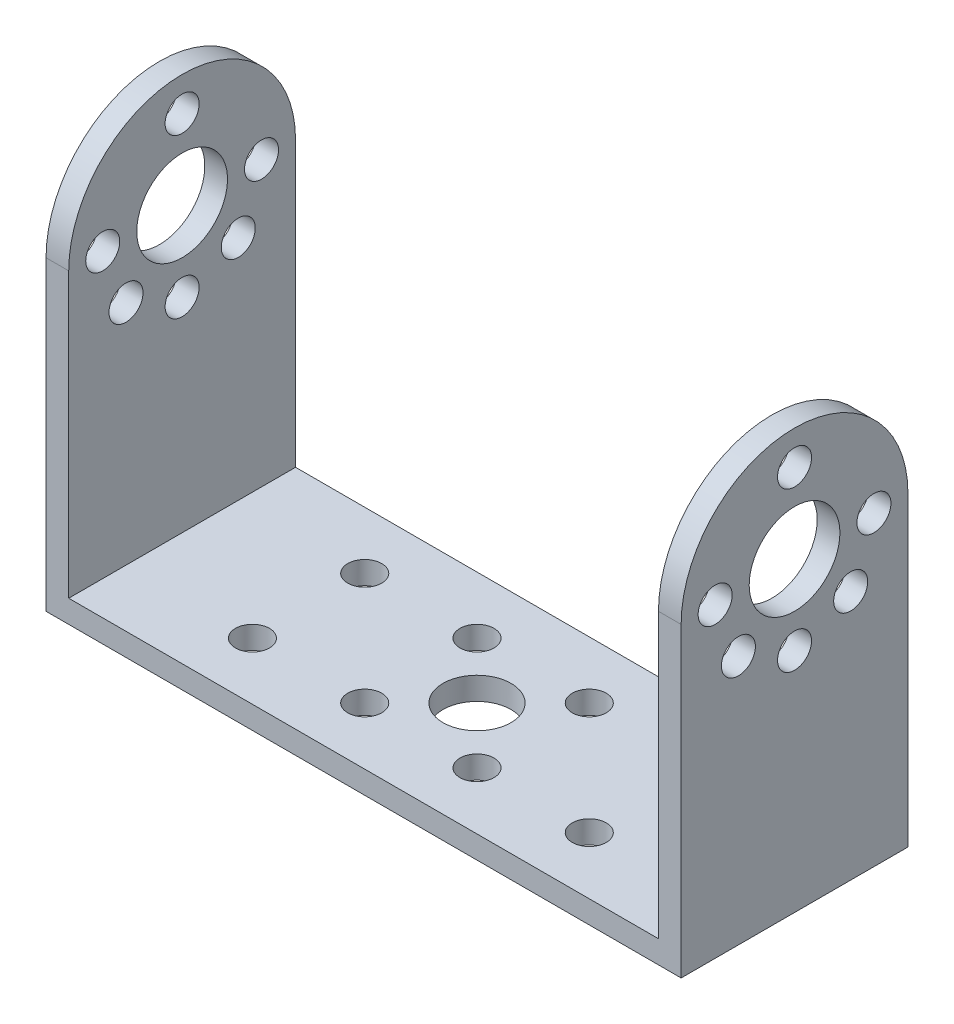
from build123d import *

# Parameters (mm, degrees)
SKETCH_1_W          = 56
SKETCH_1_H          = 20
EXTRUDE_1_DEPTH     = 2
CUT_EXTRUDE_1_REACH = 4
SKETCH_2_R          = 3
SKETCH_2_R_2        = 1.5
EXTRUDE_2_DEPTH     = 2
SKETCH_4_R          = 4
SKETCH_4_R_2        = 1.5
CUT_EXTRUDE_2_DEPTH = 2


with BuildPart() as part:
    # 草图1 → 凸台-拉伸1 (new body)
    with BuildSketch(Plane(origin=(0, 0, 0), x_dir=(1, 0, 0), z_dir=(0, 1, 0))):
        with Locations((28, 10)):
            Rectangle(SKETCH_1_W, SKETCH_1_H)
    extrude(amount=EXTRUDE_1_DEPTH)

    # 草图2 → 切除-拉伸1 (cut, up to next)
    with BuildSketch(Plane(origin=(0, 2, 0), x_dir=(1, 0, 0), z_dir=(0, 1, 0)), mode=Mode.PRIVATE) as cut_extrude_1_sk1:
        with Locations((28, 10)):
            Circle(SKETCH_2_R)
    cut_extrude_1_tool1 = extrude(cut_extrude_1_sk1.sketch, amount=-CUT_EXTRUDE_1_REACH, mode=Mode.PRIVATE) & part.part
    add(cut_extrude_1_tool1.solids().sort_by_distance((28, 2, -10))[0], mode=Mode.SUBTRACT)
    # 草图2 → 切除-拉伸1 (cut, up to next)
    with BuildSketch(Plane(origin=(0, 2, 0), x_dir=(1, 0, 0), z_dir=(0, 1, 0)), mode=Mode.PRIVATE) as cut_extrude_1_sk2:
        with Locations((32.949747468, 5.050252532)):
            Circle(SKETCH_2_R_2)
    cut_extrude_1_tool2 = extrude(cut_extrude_1_sk2.sketch, amount=-CUT_EXTRUDE_1_REACH, mode=Mode.PRIVATE) & part.part
    add(cut_extrude_1_tool2.solids().sort_by_distance((32.949747, 2, -5.050253))[0], mode=Mode.SUBTRACT)
    # 草图2 → 切除-拉伸1 (cut, up to next)
    with BuildSketch(Plane(origin=(0, 2, 0), x_dir=(1, 0, 0), z_dir=(0, 1, 0)), mode=Mode.PRIVATE) as cut_extrude_1_sk3:
        with Locations((23.050252532, 5.050252532)):
            Circle(SKETCH_2_R_2)
    cut_extrude_1_tool3 = extrude(cut_extrude_1_sk3.sketch, amount=-CUT_EXTRUDE_1_REACH, mode=Mode.PRIVATE) & part.part
    add(cut_extrude_1_tool3.solids().sort_by_distance((23.050253, 2, -5.050253))[0], mode=Mode.SUBTRACT)
    # 草图2 → 切除-拉伸1 (cut, up to next)
    with BuildSketch(Plane(origin=(0, 2, 0), x_dir=(1, 0, 0), z_dir=(0, 1, 0)), mode=Mode.PRIVATE) as cut_extrude_1_sk4:
        with Locations((23.050252532, 14.949747468)):
            Circle(SKETCH_2_R_2)
    cut_extrude_1_tool4 = extrude(cut_extrude_1_sk4.sketch, amount=-CUT_EXTRUDE_1_REACH, mode=Mode.PRIVATE) & part.part
    add(cut_extrude_1_tool4.solids().sort_by_distance((23.050253, 2, -14.949747))[0], mode=Mode.SUBTRACT)
    # 草图2 → 切除-拉伸1 (cut, up to next)
    with BuildSketch(Plane(origin=(0, 2, 0), x_dir=(1, 0, 0), z_dir=(0, 1, 0)), mode=Mode.PRIVATE) as cut_extrude_1_sk5:
        with Locations((32.949747468, 14.949747468)):
            Circle(SKETCH_2_R_2)
    cut_extrude_1_tool5 = extrude(cut_extrude_1_sk5.sketch, amount=-CUT_EXTRUDE_1_REACH, mode=Mode.PRIVATE) & part.part
    add(cut_extrude_1_tool5.solids().sort_by_distance((32.949747, 2, -14.949747))[0], mode=Mode.SUBTRACT)
    # 草图2 → 切除-拉伸1 (cut, up to next)
    with BuildSketch(Plane(origin=(0, 2, 0), x_dir=(1, 0, 0), z_dir=(0, 1, 0)), mode=Mode.PRIVATE) as cut_extrude_1_sk6:
        with Locations((13.150757595, 14.949747468)):
            Circle(SKETCH_2_R_2)
    cut_extrude_1_tool6 = extrude(cut_extrude_1_sk6.sketch, amount=-CUT_EXTRUDE_1_REACH, mode=Mode.PRIVATE) & part.part
    add(cut_extrude_1_tool6.solids().sort_by_distance((13.150758, 2, -14.949747))[0], mode=Mode.SUBTRACT)
    # 草图2 → 切除-拉伸1 (cut, up to next)
    with BuildSketch(Plane(origin=(0, 2, 0), x_dir=(1, 0, 0), z_dir=(0, 1, 0)), mode=Mode.PRIVATE) as cut_extrude_1_sk7:
        with Locations((13.150757595, 5.050252532)):
            Circle(SKETCH_2_R_2)
    cut_extrude_1_tool7 = extrude(cut_extrude_1_sk7.sketch, amount=-CUT_EXTRUDE_1_REACH, mode=Mode.PRIVATE) & part.part
    add(cut_extrude_1_tool7.solids().sort_by_distance((13.150758, 2, -5.050253))[0], mode=Mode.SUBTRACT)
    # 草图2 → 切除-拉伸1 (cut, up to next)
    with BuildSketch(Plane(origin=(0, 2, 0), x_dir=(1, 0, 0), z_dir=(0, 1, 0)), mode=Mode.PRIVATE) as cut_extrude_1_sk8:
        with Locations((42.849242405, 5.050252532)):
            Circle(SKETCH_2_R_2)
    cut_extrude_1_tool8 = extrude(cut_extrude_1_sk8.sketch, amount=-CUT_EXTRUDE_1_REACH, mode=Mode.PRIVATE) & part.part
    add(cut_extrude_1_tool8.solids().sort_by_distance((42.849242, 2, -5.050253))[0], mode=Mode.SUBTRACT)
    # 草图2 → 切除-拉伸1 (cut, up to next)
    with BuildSketch(Plane(origin=(0, 2, 0), x_dir=(1, 0, 0), z_dir=(0, 1, 0)), mode=Mode.PRIVATE) as cut_extrude_1_sk9:
        with Locations((42.849242405, 14.949747468)):
            Circle(SKETCH_2_R_2)
    cut_extrude_1_tool9 = extrude(cut_extrude_1_sk9.sketch, amount=-CUT_EXTRUDE_1_REACH, mode=Mode.PRIVATE) & part.part
    add(cut_extrude_1_tool9.solids().sort_by_distance((42.849242, 2, -14.949747))[0], mode=Mode.SUBTRACT)

    # 草图3 → 凸台-拉伸2 (add)
    with BuildSketch(Plane.ZY):
        with BuildLine():
            Line((-20, 2), (0, 2))
            Line((0, 2), (0, 27))
            ThreePointArc((0, 27), (-10, 37), (-20, 27))
            Line((-20, 27), (-20, 2))
        make_face()
    extrude_2 = extrude(amount=-EXTRUDE_2_DEPTH)

    # 草图4 → 切除-拉伸2 (cut)
    with BuildSketch(Plane.ZY):
        with Locations((-10, 27)):
            Circle(SKETCH_4_R)
        with Locations((-10, 34)):
            Circle(SKETCH_4_R_2)
        with Locations((-3, 27)):
            Circle(SKETCH_4_R_2)
        with Locations((-5.050252532, 22.050252532)):
            Circle(SKETCH_4_R_2)
        with Locations((-10, 20)):
            Circle(SKETCH_4_R_2)
        with Locations((-14.949747468, 22.050252532)):
            Circle(SKETCH_4_R_2)
        with Locations((-17, 27)):
            Circle(SKETCH_4_R_2)
    cut_extrude_2 = extrude(amount=-CUT_EXTRUDE_2_DEPTH, mode=Mode.SUBTRACT)

    # 镜向1: 凸台-拉伸2, 切除-拉伸2 across plane
    add(extrude_2.mirror(Plane.ZY.offset(-28)))
    add(cut_extrude_2.mirror(Plane.ZY.offset(-28)), mode=Mode.SUBTRACT)


solid = part.part
